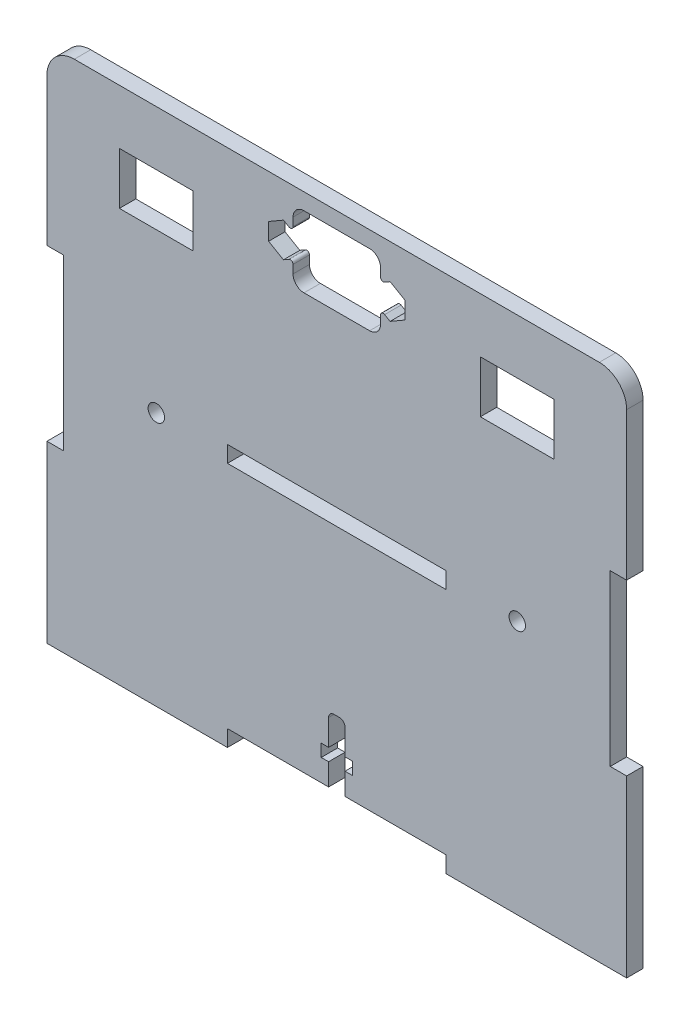
from build123d import *

# Parameters (mm, degrees)
ESBO_O1_W                = 100
ESBO_O1_H                = 95
RESSALTO_EXTRUS_O1_DEPTH = 1.5
ESBO_O3_W                = 3
ESBO_O3_H                = 32
RESSALTO_EXTRUS_O2_DEPTH = 3
ESBO_O2_R                = 1.5
ESBO_O2_W                = 40
ESBO_O2_H                = 3
CORTE_EXTRUS_O1_DEPTH    = 4
CUT_EXTRUDE7_DEPTH       = 2.5
CUT_EXTRUDE7_DEPTH_BACK  = 2.5
CUT_EXTRUDE5_DEPTH       = 2.5
CUT_EXTRUDE5_DEPTH_BACK  = 2.5
SKETCH7_W                = 13.5
SKETCH7_H                = 9.5
CUT_EXTRUDE6_DEPTH       = 2.5
CUT_EXTRUDE6_DEPTH_BACK  = 2.5
FILLET2_R                = 5


with BuildPart() as part:
    # Esboço1 → Ressalto-extrusão1 (new body, symmetric)
    with BuildSketch(Plane.XY):
        Rectangle(ESBO_O1_W, ESBO_O1_H)
    extrude(amount=RESSALTO_EXTRUS_O1_DEPTH, both=True)

    # Esboço3 → Ressalto-extrusão2 (add, through all)
    with BuildSketch(Plane.XY.offset(1.5)):
        with Locations((-51.5, 31.5)):
            Rectangle(ESBO_O3_W, ESBO_O3_H)
        with Locations((-51.5, -31.5)):
            Rectangle(ESBO_O3_W, ESBO_O3_H)
        with Locations((51.5, -31.5)):
            Rectangle(ESBO_O3_W, ESBO_O3_H)
        with Locations((51.5, 31.5)):
            Rectangle(ESBO_O3_W, ESBO_O3_H)
    extrude(amount=-RESSALTO_EXTRUS_O2_DEPTH)

    # Esboço2 → Corte-extrusão1 (cut, through all)
    with BuildSketch(Plane.XY.offset(1.5)):
        with Locations((-33, -1)):
            Circle(ESBO_O2_R)
        with Locations((33, -1)):
            Circle(ESBO_O2_R)
        with Locations((0, -46)):
            Rectangle(ESBO_O2_W, ESBO_O2_H)
        with Locations((0, -1)):
            Rectangle(ESBO_O2_W, ESBO_O2_H)
    extrude(amount=-CORTE_EXTRUS_O1_DEPTH, mode=Mode.SUBTRACT)

    # Sketch9 → Cut-Extrude7 (cut, two sides)
    with BuildSketch(Plane.XY) as cut_extrude7_sk:
        with BuildLine():
            Line((-1.5, -44.5), (1.5, -44.5))
            Line((1.5, -44.5), (1.5, -40.5))
            Line((1.5, -40.5), (2.85, -40.5))
            Line((2.85, -40.5), (2.85, -38.23))
            Line((2.85, -38.23), (1.5, -38.23))
            Line((1.5, -38.23), (1.5, -33.5))
            ThreePointArc((1.5, -33.5), (1.207106781, -32.792893219), (0.5, -32.5))
            Line((0.5, -32.5), (-0.5, -32.5))
            ThreePointArc((-0.5, -32.5), (-1.207106781, -32.792893219), (-1.5, -33.5))
            Line((-1.5, -33.5), (-1.5, -38.23))
            Line((-1.5, -38.23), (-2.85, -38.23))
            Line((-2.85, -38.23), (-2.85, -40.5))
            Line((-2.85, -40.5), (-1.5, -40.5))
            Line((-1.5, -40.5), (-1.5, -44.5))
        make_face()
    extrude(amount=CUT_EXTRUDE7_DEPTH, mode=Mode.SUBTRACT)
    extrude(cut_extrude7_sk.sketch, amount=-CUT_EXTRUDE7_DEPTH_BACK, mode=Mode.SUBTRACT)

    # Sketch6 → Cut-Extrude5 (cut, two sides)
    with BuildSketch(Plane.XY) as cut_extrude5_sk:
        with BuildLine():
            Line((-6, 44.5), (6, 44.5))
            ThreePointArc((6, 44.5), (7.414213562, 43.914213562), (8, 42.5))
            Line((8, 42.5), (8, 41))
            ThreePointArc((8, 41), (8.000003519, 40.99675088), (8.000014076, 40.993501776))
            ThreePointArc((8.000014076, 40.993501776), (8.25094791, 40.562114644), (8.750009384, 40.562655149))
            Line((8.750009384, 40.562655149), (9.75, 41.14))
            Line((9.75, 41.14), (12.469319768, 39.57))
            Line((12.469319768, 39.57), (12.469319768, 36.43))
            Line((12.469319768, 36.43), (9.75, 34.86))
            Line((9.75, 34.86), (8.750009384, 35.437344851))
            ThreePointArc((8.750009384, 35.437344851), (8.25094791, 35.437885356), (8.000014076, 35.006498224))
            ThreePointArc((8.000014076, 35.006498224), (8.000003519, 35.00324912), (8, 35))
            Line((8, 35), (8, 33.5))
            ThreePointArc((8, 33.5), (7.414213562, 32.085786438), (6, 31.5))
            Line((6, 31.5), (-6, 31.5))
            ThreePointArc((-6, 31.5), (-7.414213562, 32.085786438), (-8, 33.5))
            Line((-8, 33.5), (-8, 35))
            ThreePointArc((-8, 35), (-8.000003519, 35.00324912), (-8.000014076, 35.006498224))
            ThreePointArc((-8.000014076, 35.006498224), (-8.25094791, 35.437885356), (-8.750009384, 35.437344851))
            Line((-8.750009384, 35.437344851), (-9.75, 34.86))
            Line((-9.75, 34.86), (-12.469319768, 36.43))
            Line((-12.469319768, 36.43), (-12.469319768, 39.57))
            Line((-12.469319768, 39.57), (-9.75, 41.14))
            Line((-9.75, 41.14), (-8.750009384, 40.562655149))
            ThreePointArc((-8.750009384, 40.562655149), (-8.25094791, 40.562114644), (-8.000014076, 40.993501776))
            ThreePointArc((-8.000014076, 40.993501776), (-8.000003519, 40.99675088), (-8, 41))
            Line((-8, 41), (-8, 42.5))
            ThreePointArc((-8, 42.5), (-7.414213562, 43.914213562), (-6, 44.5))
        make_face()
    extrude(amount=CUT_EXTRUDE5_DEPTH, mode=Mode.SUBTRACT)
    extrude(cut_extrude5_sk.sketch, amount=-CUT_EXTRUDE5_DEPTH_BACK, mode=Mode.SUBTRACT)

    # Sketch7 → Cut-Extrude6 (cut, two sides)
    with BuildSketch(Plane.XY) as cut_extrude6_sk:
        with Locations((-33, 32.75)):
            Rectangle(SKETCH7_W, SKETCH7_H)
        with Locations((33, 32.75)):
            Rectangle(SKETCH7_W, SKETCH7_H)
    extrude(amount=CUT_EXTRUDE6_DEPTH, mode=Mode.SUBTRACT)
    extrude(cut_extrude6_sk.sketch, amount=-CUT_EXTRUDE6_DEPTH_BACK, mode=Mode.SUBTRACT)

    # Fillet2
    fillet2_edges = [part.edges().sort_by_distance(p)[0] for p in [
        (-53, 47.5, 0),
        (53, 47.5, 0),
    ]]
    fillet(fillet2_edges, radius=FILLET2_R)


solid = part.part
